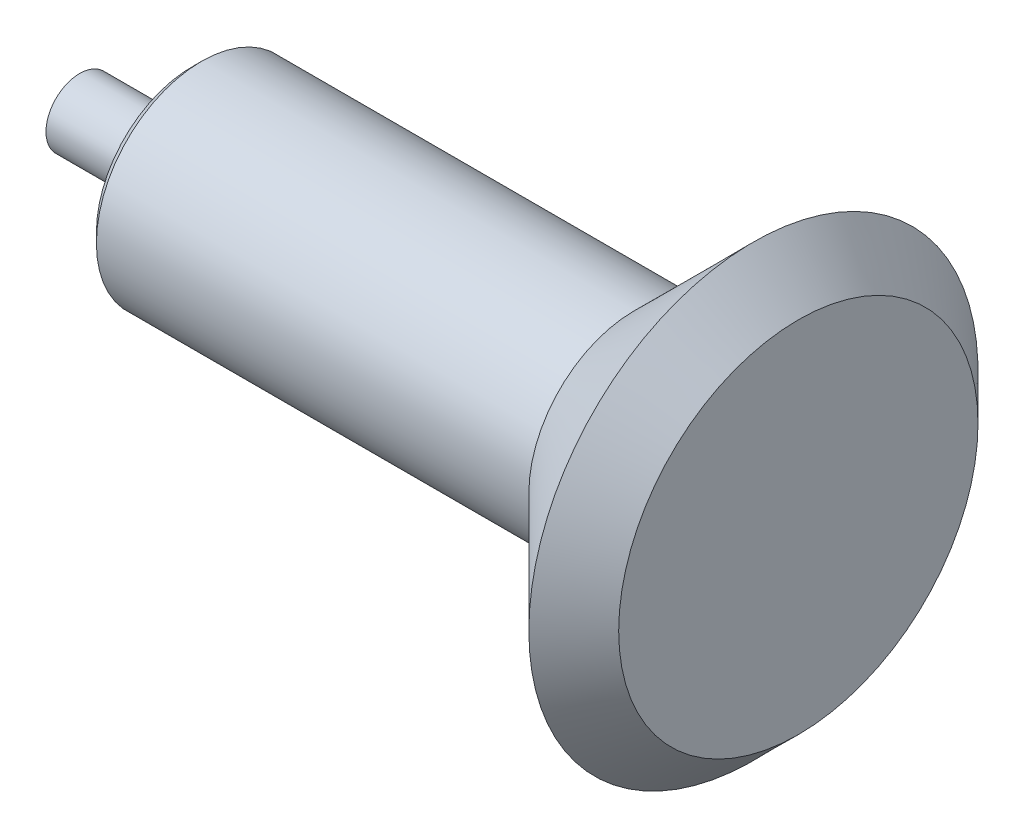
from build123d import *


with BuildPart() as part:
    # Çizim1 one side → Döndür3 (revolve)
    with BuildSketch(Plane.XY):
        Polygon((0, 7.5), (0, 0), (160, 0), (160, 40), (150, 50), (123.402702597, 23.402702597), (27.121320344, 23.402702597), (25, 21.281382254), (25, 7.5), align=None)
    revolve(axis=Axis((0, 0, 0), (1, 0, 0)))


solid = part.part
